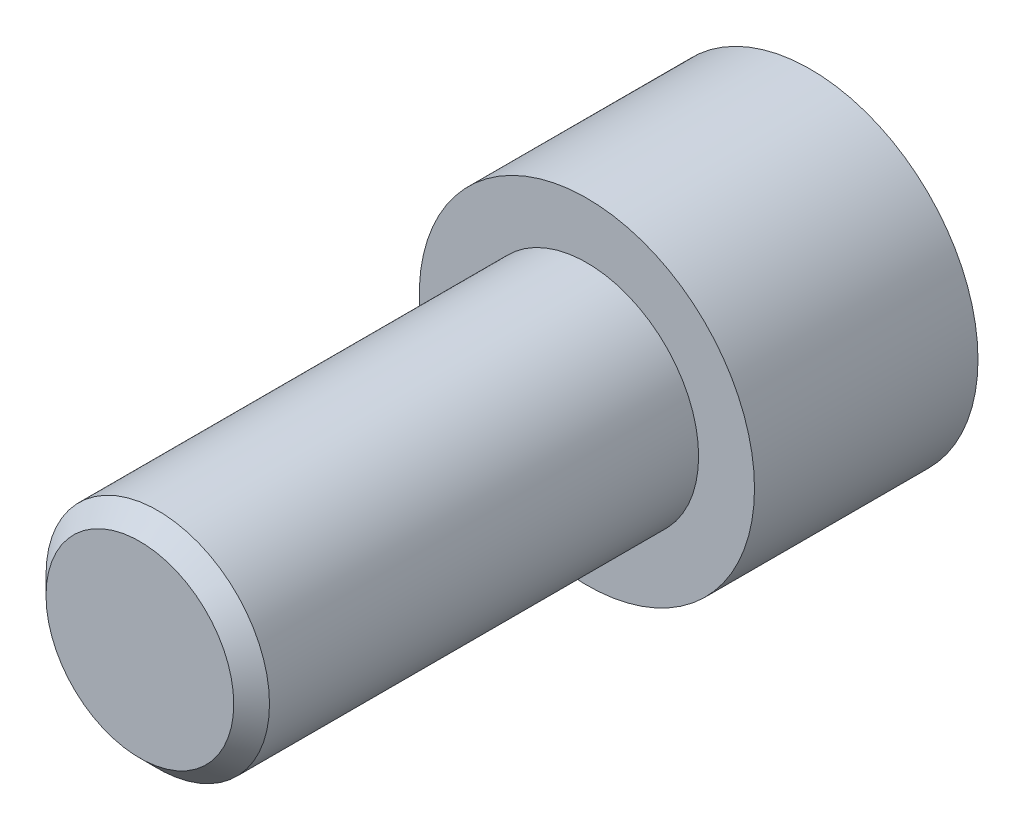
from build123d import *

# Parameters (mm, degrees)
SKETCH1_R           = 4.7625
BOSS_EXTRUDE1_DEPTH = 6.35
SKETCH2_R           = 3.175
BOSS_EXTRUDE2_DEPTH = 12.7
CHAMFER1_SIZE       = 0.508
CUT_EXTRUDE1_DEPTH  = 3.81


with BuildPart() as part:
    # Sketch1 → Boss-Extrude1 (new body)
    with BuildSketch(Plane.XY):
        Circle(SKETCH1_R)
    extrude(amount=-BOSS_EXTRUDE1_DEPTH)

    # Sketch2 → Boss-Extrude2 (add)
    with BuildSketch(Plane.XY):
        Circle(SKETCH2_R)
    extrude(amount=BOSS_EXTRUDE2_DEPTH)

    # Chamfer1
    chamfer1_edges = [part.edges().sort_by_distance(p)[0] for p in [
        (-3.175, 0, 12.7),
    ]]
    chamfer(chamfer1_edges, length=CHAMFER1_SIZE)

    # Sketch3 → Cut-Extrude1 (cut)
    with BuildSketch(Plane(origin=(0, 0, -6.35), x_dir=(-1, 0, 0), z_dir=(0, 0, -1))):
        Polygon((0, 2.932939367), (-2.54, 1.466469684), (-2.54, -1.466469684), (0, -2.932939367), (2.54, -1.466469684), (2.54, 1.466469684), align=None)
    extrude(amount=-CUT_EXTRUDE1_DEPTH, mode=Mode.SUBTRACT)


solid = part.part
